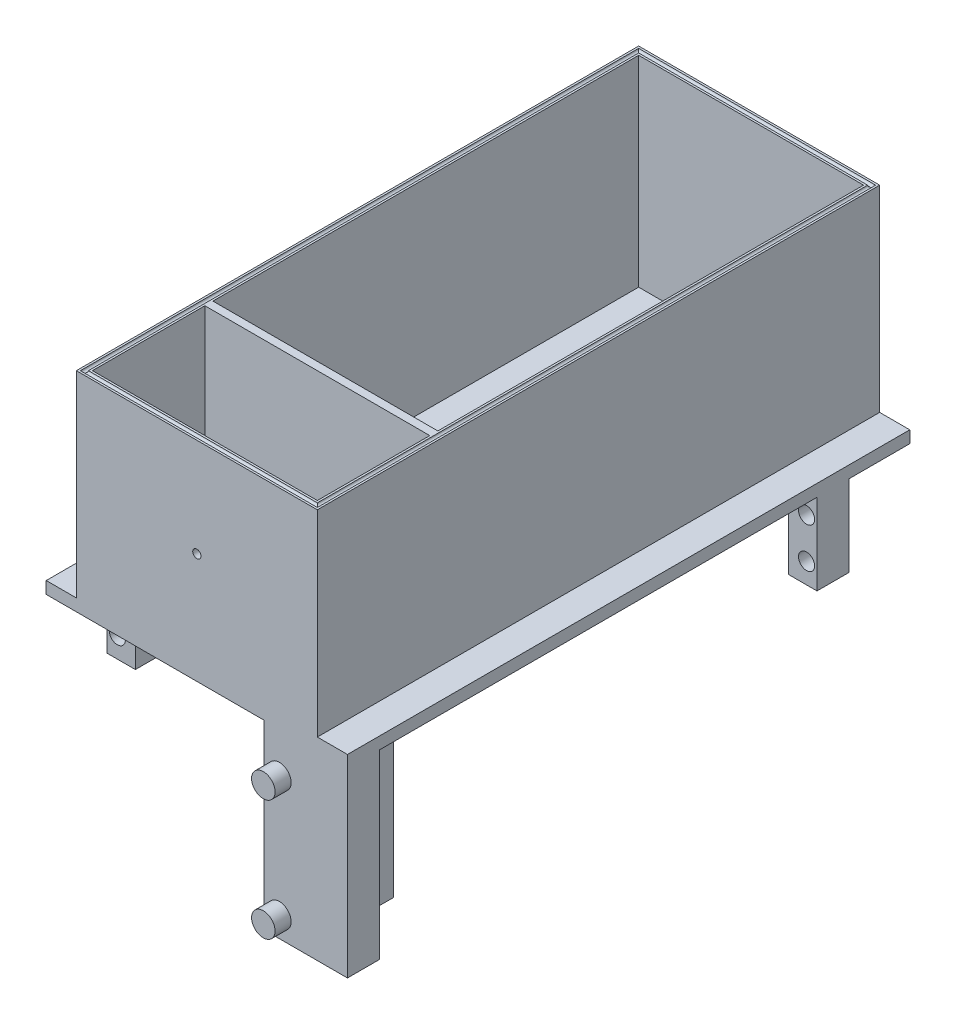
from build123d import *

# Parameters (mm, degrees)
SKETCH1_W            = 60
SKETCH1_H            = 110
BOSS_EXTRUDE1_DEPTH  = 2
SKETCH2_W            = 60
SKETCH2_H            = 110
SKETCH2_W_2          = 56
SKETCH2_H_2          = 106
BOSS_EXTRUDE2_DEPTH  = 50
SKETCH3_W            = 60
SKETCH3_H            = 30
BOSS_EXTRUDE3_DEPTH  = 2
BOSS_EXTRUDE4_DEPTH  = 50
SKETCH5_R            = 2.486759959
CUT_EXTRUDE1_DEPTH   = 30
CUT_SWEEP1_PROFILE_R = 0.5
SKETCH43_W           = 7.5
SKETCH43_H           = 140
BOSS_EXTRUDE7_DEPTH  = 3
SKETCH55_W           = 7.1
SKETCH55_H           = 8
BOSS_EXTRUDE10_DEPTH = 20.2
SKETCH56_R           = 2
CUT_EXTRUDE3_DEPTH   = 46.2
SKETCH59_R           = 2
CUT_EXTRUDE4_DEPTH   = 49.2
SKETCH60_R           = 2.925
BOSS_EXTRUDE11_DEPTH = 4
SKETCH61_R           = 2.925
BOSS_EXTRUDE12_DEPTH = 4
SKETCH62_R           = 1.025
CUT_EXTRUDE5_DEPTH   = 10
BOSS_EXTRUDE13_DEPTH = 25
SKETCH64_R           = 2.925
BOSS_EXTRUDE14_DEPTH = 4
BOSS_EXTRUDE15_DEPTH = 25
SKETCH66_R           = 2.925
BOSS_EXTRUDE16_DEPTH = 4


with BuildPart() as part:
    # Sketch1 → Boss-Extrude1 (new body)
    with BuildSketch(Plane(origin=(0, 0, 0), x_dir=(1, 0, 0), z_dir=(0, 1, 0))):
        Rectangle(SKETCH1_W, SKETCH1_H)
    extrude(amount=BOSS_EXTRUDE1_DEPTH)

    # Sketch2 → Boss-Extrude2 (add)
    with BuildSketch(Plane(origin=(0, 2, 0), x_dir=(1, 0, 0), z_dir=(0, 1, 0))):
        Rectangle(SKETCH2_W, SKETCH2_H)
        Rectangle(SKETCH2_W_2, SKETCH2_H_2, mode=Mode.SUBTRACT)
    extrude(amount=BOSS_EXTRUDE2_DEPTH)

    # Sketch3 → Boss-Extrude3 (add)
    with BuildSketch(Plane(origin=(0, 0, 0), x_dir=(1, 0, 0), z_dir=(0, 1, 0))):
        with Locations((0, -70)):
            Rectangle(SKETCH3_W, SKETCH3_H)
    extrude(amount=BOSS_EXTRUDE3_DEPTH)

    # Sketch4 → Boss-Extrude4 (add)
    with BuildSketch(Plane(origin=(0, 2, 0), x_dir=(1, 0, 0), z_dir=(0, 1, 0))):
        Polygon((-28, -55), (-30, -55), (-30, -85), (30, -85), (30, -55), (28, -55), (28, -83), (-28, -83), align=None)
    extrude(amount=BOSS_EXTRUDE4_DEPTH)

    # Sketch5 → Cut-Extrude1 (cut)
    with BuildSketch(Plane.XY.offset(55)):
        with Locations((0, 15.890944925)):
            Circle(SKETCH5_R)
    extrude(amount=-CUT_EXTRUDE1_DEPTH, mode=Mode.SUBTRACT)

    # Cut-Sweep1: sweep along a path in Sketch6
    with BuildLine(Plane(origin=(0, 52, 0), x_dir=(1, 0, 0), z_dir=(0, 1, 0))) as cut_sweep1_path:
        Line((-29, 54), (-29, -84))
        Line((-29, -84), (29, -84))
        Line((29, -84), (29, 54))
        Line((29, 54), (-29, 54))
    # Cut-Sweep1 profile (on start of the path) → Cut-Sweep1 (sweep, cut)
    with BuildSketch(Plane(origin=(-29, 52, -54), x_dir=(1, 0, 0), z_dir=(0, 0, 1))):
        Circle(CUT_SWEEP1_PROFILE_R)
    sweep(path=cut_sweep1_path.line, transition=Transition.RIGHT, mode=Mode.SUBTRACT)

    # Sketch43 → Boss-Extrude7 (add)
    with BuildSketch(Plane.XZ):
        with Locations((33.75, 15)):
            Rectangle(SKETCH43_W, SKETCH43_H)
        Polygon((-30, -55), (-37.5, -55), (-37.5, 85), (-30, 85), (-30, 55), align=None)
    extrude(amount=-BOSS_EXTRUDE7_DEPTH)

    # Sketch55 → Boss-Extrude10 (add)
    with BuildSketch(Plane.XZ):
        with Locations((-33.95, 65.9)):
            Rectangle(SKETCH55_W, SKETCH55_H)
        Polygon((9.6, 69.9), (9.6, 61.9), (25.881976889, 61.9), (25.881976889, 77), (37.5, 77), (37.5, 85), (16.7, 85), (16.7, 69.9), align=None)
        with Locations((33.95, -35.9)):
            Rectangle(SKETCH55_W, SKETCH55_H)
        Polygon((-9.6, -39.9), (-9.6, -31.9), (-24.7, -31.9), (-24.7, -47), (-37.5, -47), (-37.5, -55), (-16.7, -55), (-16.7, -39.9), align=None)
    extrude(amount=BOSS_EXTRUDE10_DEPTH)

    # Sketch56 → Cut-Extrude3 (cut)
    with BuildSketch(Plane.XY.offset(85)):
        with Locations((-34.9, -15.1)):
            Circle(SKETCH56_R)
        with Locations((-34.9, -5.1)):
            Circle(SKETCH56_R)
        with Locations((14.1, -15.1)):
            Circle(SKETCH56_R)
        with Locations((14.1, -5.1)):
            Circle(SKETCH56_R)
    extrude(amount=-CUT_EXTRUDE3_DEPTH, mode=Mode.SUBTRACT)

    # Sketch59 → Cut-Extrude4 (cut)
    with BuildSketch(Plane(origin=(0, 0, -55), x_dir=(-1, 0, 0), z_dir=(0, 0, -1))):
        with Locations((-34.9, -15.1)):
            Circle(SKETCH59_R)
        with Locations((-34.9, -5.1)):
            Circle(SKETCH59_R)
        with Locations((14.1, -5.1)):
            Circle(SKETCH59_R)
        with Locations((14.1, -15.1)):
            Circle(SKETCH59_R)
    extrude(amount=-CUT_EXTRUDE4_DEPTH, mode=Mode.SUBTRACT)

    # Sketch60 → Boss-Extrude11 (add)
    with BuildSketch(Plane(origin=(0, 0, -55), x_dir=(-1, 0, 0), z_dir=(0, 0, -1))):
        with Locations((20.55, -10.1)):
            Circle(SKETCH60_R)
    extrude(amount=BOSS_EXTRUDE11_DEPTH)

    # Sketch61 → Boss-Extrude12 (add)
    with BuildSketch(Plane.XY.offset(85)):
        with Locations((20.55, -10.1)):
            Circle(SKETCH61_R)
    extrude(amount=BOSS_EXTRUDE12_DEPTH)

    # Sketch62 → Cut-Extrude5 (cut)
    with BuildSketch(Plane.XY.offset(85)):
        with Locations((0, 27.5)):
            Circle(SKETCH62_R)
    extrude(amount=-CUT_EXTRUDE5_DEPTH, mode=Mode.SUBTRACT)

    # Sketch63 → Boss-Extrude13 (add)
    with BuildSketch(Plane.XZ.offset(20.2)):
        Polygon((16.7, 69.9), (9.6, 69.9), (9.6, 61.9), (25.881976889, 61.9), (25.881976889, 77), (37.5, 77), (37.5, 85), (16.7, 85), align=None)
    extrude(amount=BOSS_EXTRUDE13_DEPTH)

    # Sketch64 → Boss-Extrude14 (add)
    with BuildSketch(Plane.XY.offset(85)):
        with Locations((20.55, -40.1)):
            Circle(SKETCH64_R)
    extrude(amount=BOSS_EXTRUDE14_DEPTH)

    # Sketch65 → Boss-Extrude15 (add)
    with BuildSketch(Plane.XZ.offset(20.2)):
        Polygon((-16.7, -39.9), (-9.6, -39.9), (-9.6, -31.9), (-24.7, -31.9), (-24.7, -47), (-37.5, -47), (-37.5, -55), (-16.7, -55), align=None)
    extrude(amount=BOSS_EXTRUDE15_DEPTH)

    # Sketch66 → Boss-Extrude16 (add)
    with BuildSketch(Plane(origin=(0, 0, -55), x_dir=(-1, 0, 0), z_dir=(0, 0, -1))):
        with Locations((20.55, -40.1)):
            Circle(SKETCH66_R)
    extrude(amount=BOSS_EXTRUDE16_DEPTH)


solid = part.part
